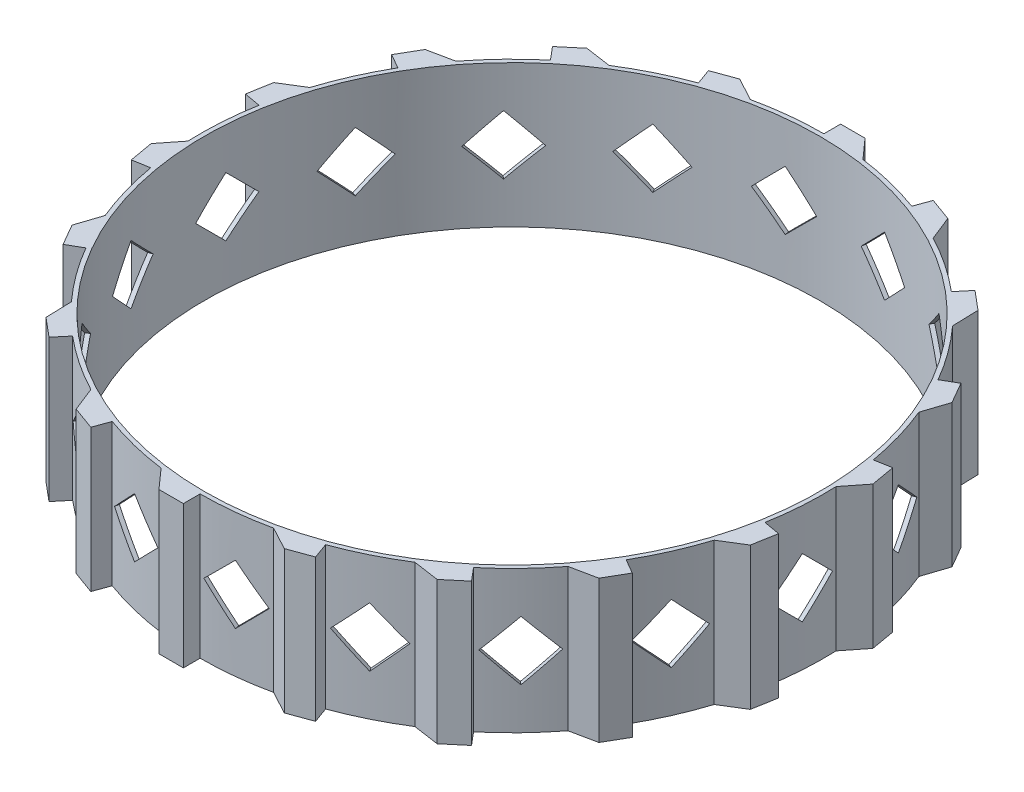
from build123d import *

# Parameters (mm, degrees)
SKETCH1_R           = 36.75
BOSS_EXTRUDE1_DEPTH = 17
CUT_EXTRUDE1_DEPTH  = 138
CIRPATTERN1_COUNT   = 18


with BuildPart() as part:
    # Sketch1 → Boss-Extrude1 (new body)
    with BuildSketch(Plane(origin=(0, 0, 0), x_dir=(1, 0, 0), z_dir=(0, 1, 0))):
        with BuildLine():
            Line((0, 37.25), (0, 39.25))
            Line((0, 39.25), (2.915832529, 39.25))
            Line((2.915832529, 39.25), (5, 36.912904248))
            ThreePointArc((5, 36.912904248), (7.685337322, 36.448567739), (10.329540446, 35.789147715))
            ThreePointArc((10.329540446, 35.789147715), (11.541581461, 35.416866002), (12.740250339, 35.003550124))
            Line((12.740250339, 35.003550124), (13.424290626, 36.882935366))
            Line((13.424290626, 36.882935366), (16.164276936, 35.885661906))
            Line((16.164276936, 35.885661906), (17.323419905, 32.976683017))
            ThreePointArc((17.323419905, 32.976683017), (19.687999132, 31.62190997), (21.947202364, 30.097887108))
            ThreePointArc((21.947202364, 30.097887108), (22.958820517, 29.333514288), (23.943838461, 28.535155506))
            Line((23.943838461, 28.535155506), (25.22941368, 30.067244392))
            Line((25.22941368, 30.067244392), (27.463070986, 28.192983371))
            Line((27.463070986, 28.192983371), (27.557379704, 25.06298713))
            ThreePointArc((27.557379704, 25.06298713), (29.315997683, 22.981183169), (30.917707771, 20.776377119))
            ThreePointArc((30.917707771, 20.776377119), (31.606886983, 19.712107834), (32.259446291, 18.625))
            Line((32.259446291, 18.625), (33.991497099, 19.625))
            Line((33.991497099, 19.625), (35.449413363, 17.099814957))
            Line((35.449413363, 17.099814957), (34.467512806, 14.126325105))
            ThreePointArc((34.467512806, 14.126325105), (35.408054255, 11.568586512), (36.159081324, 8.948929422))
            ThreePointArc((36.159081324, 8.948929422), (36.44269641, 7.713130256), (36.6840888, 6.468394618))
            Line((36.6840888, 6.468394618), (38.653704306, 6.815690973))
            Line((38.653704306, 6.815690973), (39.160033311, 3.944156493))
            Line((39.160033311, 3.944156493), (37.220355178, 1.48581979))
            ThreePointArc((37.220355178, 1.48581979), (37.229376917, -1.239352413), (37.039136018, -3.957891235))
            ThreePointArc((37.039136018, -3.957891235), (36.882978814, -5.216164664), (36.6840888, -6.468394618))
            Line((36.6840888, -6.468394618), (38.653704306, -6.815690973))
            Line((38.653704306, -6.815690973), (38.147375301, -9.687225454))
            Line((38.147375301, -9.687225454), (35.483873401, -11.33389732))
            ThreePointArc((35.483873401, -11.33389732), (34.560287275, -13.897807146), (33.451724269, -16.387331797))
            ThreePointArc((33.451724269, -16.387331797), (32.874629638, -17.516313144), (32.259446291, -18.625))
            Line((32.259446291, -18.625), (33.991497099, -19.625))
            Line((33.991497099, -19.625), (32.533580834, -22.150185043))
            Line((32.533580834, -22.150185043), (29.467512806, -22.786579143))
            ThreePointArc((29.467512806, -22.786579143), (27.722716933, -24.879981227), (25.829540878, -26.840218293))
            ThreePointArc((25.829540878, -26.840218293), (24.90111495, -27.703735746), (23.943838461, -28.535155506))
            Line((23.943838461, -28.535155506), (25.22941368, -30.067244392))
            Line((25.22941368, -30.067244392), (22.995756375, -31.941505414))
            Line((22.995756375, -31.941505414), (19.896935272, -31.490863227))
            ThreePointArc((19.896935272, -31.490863227), (17.541377784, -32.861262383), (15.091933654, -34.055778344))
            ThreePointArc((15.091933654, -34.055778344), (13.924158297, -34.549678952), (12.740250339, -35.003550124))
            Line((12.740250339, -35.003550124), (13.424290626, -36.882935366))
            Line((13.424290626, -36.882935366), (10.684304315, -37.880208825))
            Line((10.684304315, -37.880208825), (7.926493697, -36.39688445))
            ThreePointArc((7.926493697, -36.39688445), (5.244289592, -36.878990315), (2.534016498, -37.163708916))
            ThreePointArc((2.534016498, -37.163708916), (1.267742655, -37.228420979), (0, -37.25))
            Line((0, -37.25), (0, -39.25))
            Line((0, -39.25), (-2.915832529, -39.25))
            Line((-2.915832529, -39.25), (-5, -36.912904248))
            ThreePointArc((-5, -36.912904248), (-7.685337322, -36.448567739), (-10.329540446, -35.789147715))
            ThreePointArc((-10.329540446, -35.789147715), (-11.541581461, -35.416866002), (-12.740250339, -35.003550124))
            Line((-12.740250339, -35.003550124), (-13.424290626, -36.882935366))
            Line((-13.424290626, -36.882935366), (-16.164276936, -35.885661906))
            Line((-16.164276936, -35.885661906), (-17.323419905, -32.976683017))
            ThreePointArc((-17.323419905, -32.976683017), (-19.687999132, -31.62190997), (-21.947202364, -30.097887108))
            ThreePointArc((-21.947202364, -30.097887108), (-22.958820517, -29.333514288), (-23.943838461, -28.535155506))
            Line((-23.943838461, -28.535155506), (-25.22941368, -30.067244392))
            Line((-25.22941368, -30.067244392), (-27.463070986, -28.192983371))
            Line((-27.463070986, -28.192983371), (-27.557379704, -25.06298713))
            ThreePointArc((-27.557379704, -25.06298713), (-29.315997683, -22.981183169), (-30.917707771, -20.776377119))
            ThreePointArc((-30.917707771, -20.776377119), (-31.606886983, -19.712107834), (-32.259446291, -18.625))
            Line((-32.259446291, -18.625), (-33.991497099, -19.625))
            Line((-33.991497099, -19.625), (-35.449413363, -17.099814957))
            Line((-35.449413363, -17.099814957), (-34.467512806, -14.126325105))
            ThreePointArc((-34.467512806, -14.126325105), (-35.408054255, -11.568586512), (-36.159081324, -8.948929422))
            ThreePointArc((-36.159081324, -8.948929422), (-36.44269641, -7.713130256), (-36.6840888, -6.468394618))
            Line((-36.6840888, -6.468394618), (-38.653704306, -6.815690973))
            Line((-38.653704306, -6.815690973), (-39.160033311, -3.944156493))
            Line((-39.160033311, -3.944156493), (-37.220355178, -1.48581979))
            ThreePointArc((-37.220355178, -1.48581979), (-37.229376917, 1.239352413), (-37.039136018, 3.957891235))
            ThreePointArc((-37.039136018, 3.957891235), (-36.882978814, 5.216164664), (-36.6840888, 6.468394618))
            Line((-36.6840888, 6.468394618), (-38.653704306, 6.815690973))
            Line((-38.653704306, 6.815690973), (-38.147375301, 9.687225454))
            Line((-38.147375301, 9.687225454), (-35.483873401, 11.33389732))
            ThreePointArc((-35.483873401, 11.33389732), (-34.560287275, 13.897807146), (-33.451724269, 16.387331797))
            ThreePointArc((-33.451724269, 16.387331797), (-32.874629638, 17.516313144), (-32.259446291, 18.625))
            Line((-32.259446291, 18.625), (-33.991497099, 19.625))
            Line((-33.991497099, 19.625), (-32.533580834, 22.150185043))
            Line((-32.533580834, 22.150185043), (-29.467512806, 22.786579143))
            ThreePointArc((-29.467512806, 22.786579143), (-27.722716933, 24.879981227), (-25.829540878, 26.840218293))
            ThreePointArc((-25.829540878, 26.840218293), (-24.90111495, 27.703735746), (-23.943838461, 28.535155506))
            Line((-23.943838461, 28.535155506), (-25.22941368, 30.067244392))
            Line((-25.22941368, 30.067244392), (-22.995756375, 31.941505414))
            Line((-22.995756375, 31.941505414), (-19.896935272, 31.490863227))
            ThreePointArc((-19.896935272, 31.490863227), (-17.541377784, 32.861262383), (-15.091933654, 34.055778344))
            ThreePointArc((-15.091933654, 34.055778344), (-13.924158297, 34.549678952), (-12.740250339, 35.003550124))
            Line((-12.740250339, 35.003550124), (-13.424290626, 36.882935366))
            Line((-13.424290626, 36.882935366), (-10.684304315, 37.880208825))
            Line((-10.684304315, 37.880208825), (-7.926493697, 36.39688445))
            ThreePointArc((-7.926493697, 36.39688445), (-5.244289592, 36.878990315), (-2.534016498, 37.163708916))
            ThreePointArc((-2.534016498, 37.163708916), (-1.267742655, 37.228420979), (0, 37.25))
        make_face()
        Circle(SKETCH1_R, mode=Mode.SUBTRACT)
    extrude(amount=BOSS_EXTRUDE1_DEPTH)

    # Sketch2 → Cut-Extrude1 (cut)
    with BuildSketch(Plane(origin=(0, 0, 0), x_dir=(0, 0, -1), z_dir=(1, 0, 0))):
        Polygon((1.044246492, 8.5), (-2.491287414, 12.035533906), (-6.02682132, 8.5), (-2.491287414, 4.964466094), align=None)
    cut_extrude1 = extrude(amount=CUT_EXTRUDE1_DEPTH, mode=Mode.SUBTRACT)

    # CirPattern1: Cut-Extrude1 ×18 about axis
    cirpattern1_axis = Axis((0, 17, 0), (0, -1, 0))
    for i in range(1, CIRPATTERN1_COUNT):
        add(cut_extrude1.rotate(cirpattern1_axis, i * 360 / CIRPATTERN1_COUNT), mode=Mode.SUBTRACT)


solid = part.part
